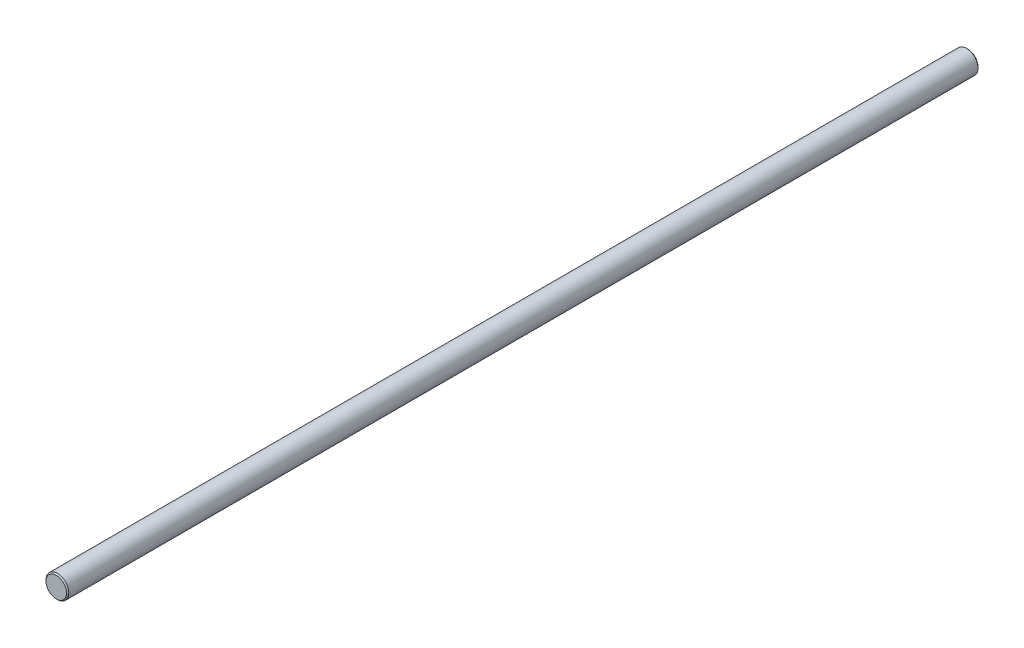
from build123d import *

# Parameters (mm, degrees)
ESBO_O1_R                = 5
RESSALTO_EXTRUS_O1_DEPTH = 400
CHANFRO1_SIZE            = 0.5


with BuildPart() as part:
    # Esboço1 → Ressalto-extrusão1 (new body)
    with BuildSketch(Plane.XY):
        Circle(ESBO_O1_R)
    extrude(amount=RESSALTO_EXTRUS_O1_DEPTH)

    # Chanfro1
    chanfro1_edges = [part.edges().sort_by_distance(p)[0] for p in [
        (-5, 0, 0),
        (-5, 0, 400),
    ]]
    chamfer(chanfro1_edges, length=CHANFRO1_SIZE)


solid = part.part
